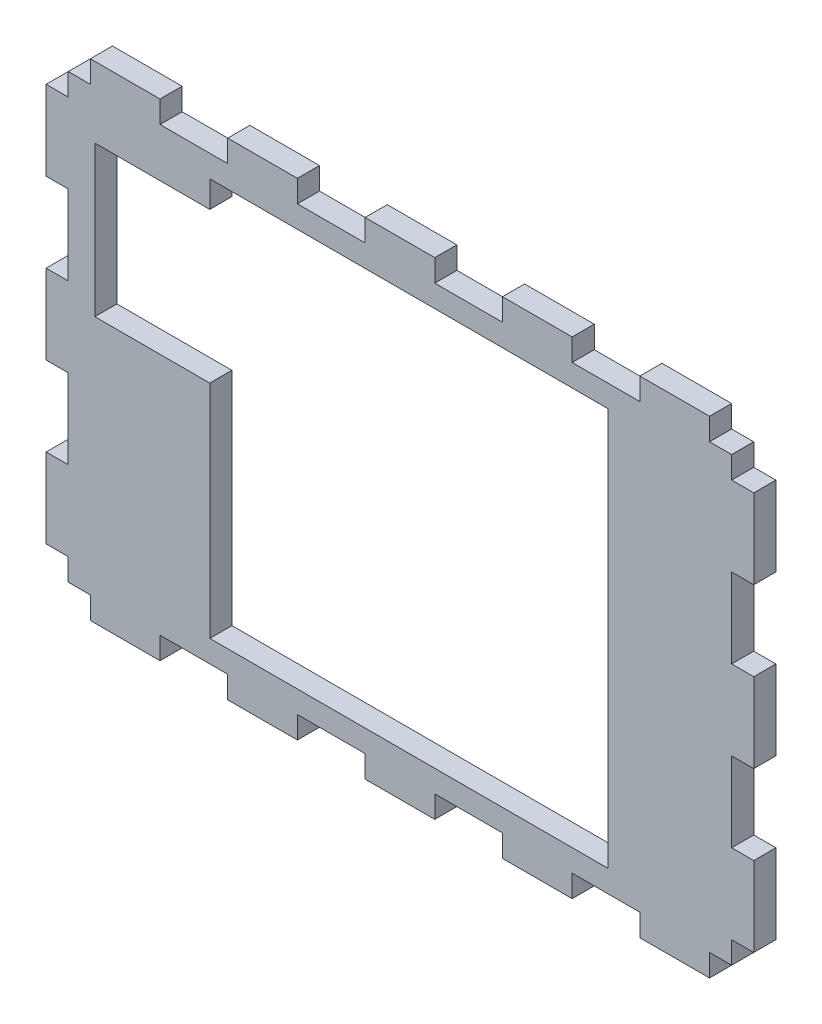
from build123d import *

# Parameters (mm, degrees)
BOSS_EXTRUDE1_DEPTH = 5
CUT_EXTRUDE1_DEPTH  = 6


with BuildPart() as part:
    # Sketch1 → Boss-Extrude1 (new body)
    with BuildSketch(Plane.XY):
        Polygon((-75, 50), (-70, 50), (-70, 55), (-54.25, 55), (-54.25, 50), (-38.9375, 50), (-38.9375, 55), (-23.1875, 55), (-23.1875, 50), (-7.875, 50), (-7.875, 55), (7.875, 55), (7.875, 50), (23.1875, 50), (23.1875, 55), (38.9375, 55), (38.9375, 50), (54.25, 50), (54.25, 55), (70, 55), (70, 50), (75, 50), (75, 45), (80, 45), (80, 27), (75, 27), (75, 9), (80, 9), (80, -9), (75, -9), (75, -27), (80, -27), (80, -45), (75, -45), (75, -50), (70, -50), (70, -55), (54.25, -55), (54.25, -50), (38.9375, -50), (38.9375, -55), (23.1875, -55), (23.1875, -50), (7.875, -50), (7.875, -55), (-7.875, -55), (-7.875, -50), (-23.1875, -50), (-23.1875, -55), (-38.9375, -55), (-38.9375, -50), (-54.25, -50), (-54.25, -55), (-70, -55), (-70, -50), (-75, -50), (-75, -45), (-80, -45), (-80, -27), (-75, -27), (-75, -9), (-80, -9), (-80, 9), (-75, 9), (-75, 27), (-80, 27), (-80, 45), (-75, 45), align=None)
    extrude(amount=BOSS_EXTRUDE1_DEPTH)

    # Sketch2 → Cut-Extrude1 (cut, through all)
    with BuildSketch(Plane(origin=(0, 0, 0), x_dir=(-1, 0, 0), z_dir=(0, 0, -1))):
        Polygon((-47, 45), (43, 45), (43, 39), (69, 39), (69, 5), (43, 5), (43, -45), (-47, -45), align=None)
    extrude(amount=-CUT_EXTRUDE1_DEPTH, mode=Mode.SUBTRACT)


solid = part.part
